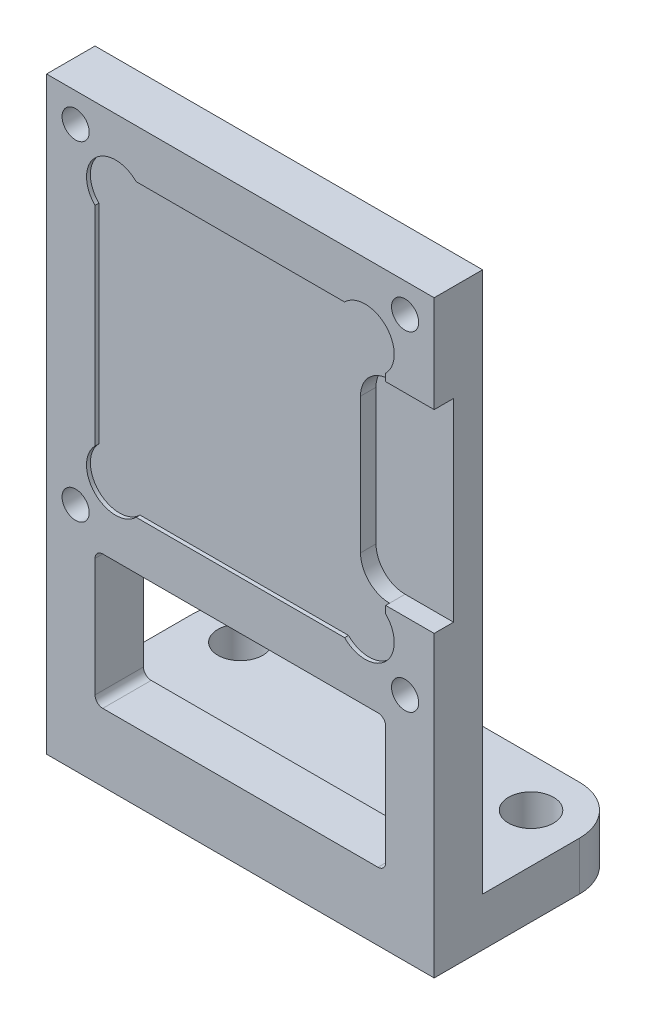
from build123d import *

# Parameters (mm, degrees)
BOSS_EXTRUDE1_DEPTH     = 12.7
SKETCH2_W               = 19.05
SKETCH2_H               = 19.05
CUT_EXTRUDE1_DEPTH      = 0.254
SKETCH3_W               = 3.175
SKETCH3_H               = 12.7
CUT_EXTRUDE2_DEPTH      = 1.27
SKETCH4_R               = 1.905
CUT_EXTRUDE3_DEPTH      = 0.254
MIRROR2_COPY_1_SKETCH_R = 1.905
MIRROR2_COPY_1_DEPTH    = 0.254
CUT_EXTRUDE4_DEPTH      = 1.016
FILLET1_R               = 3.175
F_2_56_TAPPED_HOLE1_D   = 1.778
SKETCH8_W               = 19.05
SKETCH8_H               = 8.763
CUT_EXTRUDE5_DEPTH      = 13.7
FILLET2_R               = 0.508
F_4_CLEARANCE_HOLE1_D   = 2.9464


with BuildPart() as part:
    # Sketch1 → Boss-Extrude1 (new body, symmetric)
    with BuildSketch(Plane(origin=(0, 0, 0), x_dir=(0, 0, -1), z_dir=(1, 0, 0))):
        Polygon((0, 12.7), (0, -25.908), (12.7, -25.908), (12.7, -22.733), (3.175, -22.733), (3.175, 12.7), align=None)
    extrude(amount=BOSS_EXTRUDE1_DEPTH, both=True)

    # Sketch2 → Cut-Extrude1 (cut)
    with BuildSketch(Plane.XY):
        Rectangle(SKETCH2_W, SKETCH2_H)
    extrude(amount=-CUT_EXTRUDE1_DEPTH, mode=Mode.SUBTRACT)

    # Sketch3 → Cut-Extrude2 (cut)
    with BuildSketch(Plane.XY):
        with Locations((11.1125, 0)):
            Rectangle(SKETCH3_W, SKETCH3_H)
    extrude(amount=-CUT_EXTRUDE2_DEPTH, mode=Mode.SUBTRACT)

    # Sketch4 → Cut-Extrude3 (cut)
    with BuildSketch(Plane.XY):
        with Locations((8.177961582, 8.177961582)):
            Circle(SKETCH4_R)
    cut_extrude3 = extrude(amount=-CUT_EXTRUDE3_DEPTH, mode=Mode.SUBTRACT)

    # Mirror1: Cut-Extrude3 across plane
    add(cut_extrude3.mirror(Plane(origin=(0, 0, 0), x_dir=(0, 0, 1), z_dir=(1, 0, 0))), mode=Mode.SUBTRACT)

    # Mirror2: Cut-Extrude3 across plane
    add(cut_extrude3.mirror(Plane.ZX), mode=Mode.SUBTRACT)

    # Mirror2 copy 1 sketch → Mirror2 copy 1 (cut)
    with BuildSketch(Plane(origin=(0, 0, 0), x_dir=(-1, 0, 0), z_dir=(0, 0, 1))):
        with Locations((8.177961582, 8.177961582)):
            Circle(MIRROR2_COPY_1_SKETCH_R)
    extrude(amount=-MIRROR2_COPY_1_DEPTH, mode=Mode.SUBTRACT)

    # Sketch5 → Cut-Extrude4 (cut)
    with BuildSketch(Plane.XY.offset(-0.254)):
        with BuildLine():
            Line((7.62, 4.445), (7.62, -4.445))
            ThreePointArc((7.62, -4.445), (8.177961582, -5.792038418), (9.525, -6.35))
            Line((9.525, -6.35), (9.525, 6.35))
            ThreePointArc((9.525, 6.35), (8.177961582, 5.792038418), (7.62, 4.445))
        make_face()
    extrude(amount=-CUT_EXTRUDE4_DEPTH, mode=Mode.SUBTRACT)

    # Fillet1
    fillet1_edges = [part.edges().sort_by_distance(p)[0] for p in [
        (12.7, -24.3205, -12.7),
        (-12.7, -24.3205, -12.7),
    ]]
    fillet(fillet1_edges, radius=FILLET1_R)

    # #2-56 Tapped Hole1 (through all)
    with Locations(Plane.XY):
        with Locations((-10.795, 10.795), (10.795, 10.795), (10.795, -10.795), (-10.795, -10.795)):
            Hole(F_2_56_TAPPED_HOLE1_D / 2)

    # Sketch8 → Cut-Extrude5 (cut, through all)
    with BuildSketch(Plane.XY):
        with Locations((0, -17.0815)):
            Rectangle(SKETCH8_W, SKETCH8_H)
    extrude(amount=-CUT_EXTRUDE5_DEPTH, mode=Mode.SUBTRACT)

    # Fillet2
    fillet2_edges = [part.edges().sort_by_distance(p)[0] for p in [
        (-9.525, -21.463, -1.5875),
        (-9.525, -12.7, -1.5875),
        (9.525, -12.7, -1.5875),
        (9.525, -21.463, -1.5875),
    ]]
    fillet(fillet2_edges, radius=FILLET2_R)

    # #4 Clearance Hole1 (through all)
    with Locations(Plane(origin=(0, -22.733, 0), x_dir=(1, 0, 0), z_dir=(0, 1, 0))):
        with Locations((-9.525, 9.525), (9.525, 9.525)):
            Hole(F_4_CLEARANCE_HOLE1_D / 2)


solid = part.part
